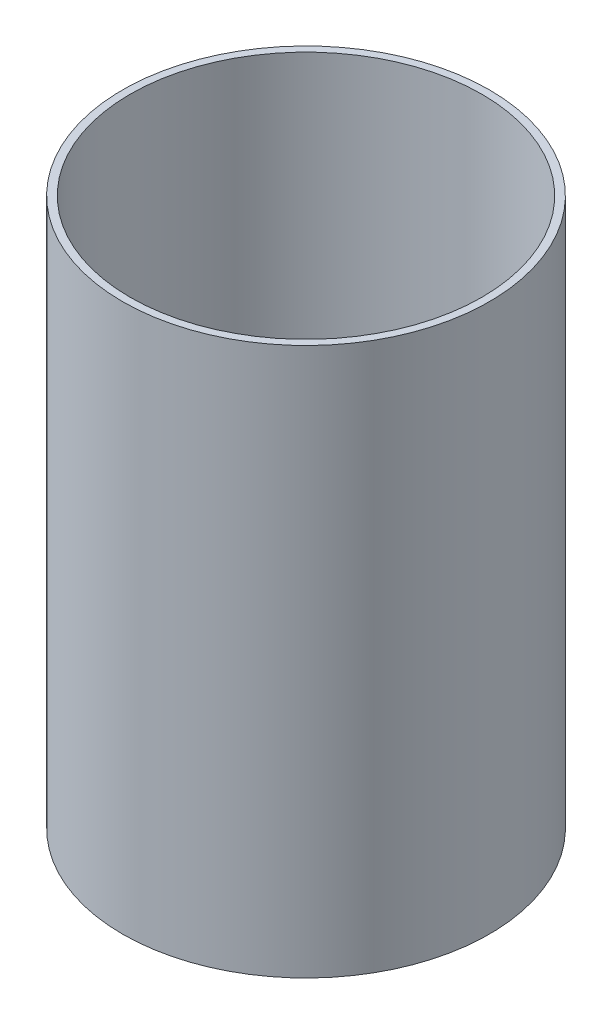
from build123d import *

# Parameters (mm, degrees)
ESQUISSE1_R        = 36.5
BOSS_EXTRU_1_DEPTH = 109
COQUE1_T           = -1.5


with BuildPart() as part:
    # Esquisse1 → Boss.-Extru.1 (new body)
    with BuildSketch(Plane(origin=(0, 0, 0), x_dir=(1, 0, 0), z_dir=(0, 1, 0))):
        with Locations(Location((0, 0, 0), (0, 0, 270))):
            Circle(ESQUISSE1_R)
    extrude(amount=BOSS_EXTRU_1_DEPTH)

    # Coque1
    coque1_openings = [part.faces().sort_by_distance(p)[0] for p in [
        (0, 109, 0),
    ]]
    offset(amount=COQUE1_T, openings=coque1_openings, kind=Kind.INTERSECTION)


solid = part.part
